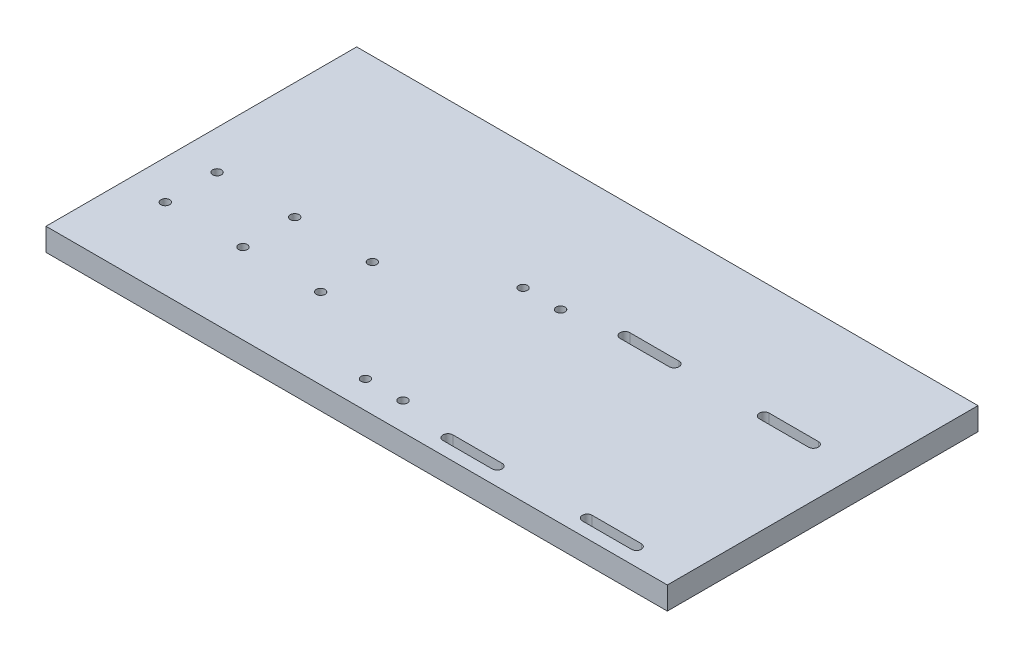
from build123d import *

# Parameters (mm, degrees)
SKETCH1_W                                      = 304.8
SKETCH1_H                                      = 152.4
BOSS_EXTRUDE1_DEPTH                            = 11.1125
CUT_EXTRUDE1_DEPTH                             = 11.1125
CUT_EXTRUDE2_REACH                             = 143.224
SKETCH5_W                                      = 24.13
SKETCH5_H                                      = 2.677814457
SKETCH5_H_2                                    = 2.54
CBORE_FOR_8_SOCKET_HEAD_CAP_SCREW1_D           = 4.3053
CBORE_FOR_8_SOCKET_HEAD_CAP_SCREW1_DEPTH       = 11.1125
CBORE_FOR_8_SOCKET_HEAD_CAP_SCREW1_CBORE_D     = 7.9375
CBORE_FOR_8_SOCKET_HEAD_CAP_SCREW1_CBORE_DEPTH = 4.1656
CBORE_FOR_8_SOCKET_HEAD_CAP_SCREW3_D           = 4.3053
CBORE_FOR_8_SOCKET_HEAD_CAP_SCREW3_DEPTH       = 11.1125
CBORE_FOR_8_SOCKET_HEAD_CAP_SCREW3_CBORE_D     = 7.9375
CBORE_FOR_8_SOCKET_HEAD_CAP_SCREW3_CBORE_DEPTH = 4.1656


with BuildPart() as part:
    # Sketch1 → Boss-Extrude1 (new body)
    with BuildSketch(Plane(origin=(0, 0, 0), x_dir=(1, 0, 0), z_dir=(0, 1, 0))):
        with Locations((152.4, 76.2)):
            Rectangle(SKETCH1_W, SKETCH1_H)
    extrude(amount=BOSS_EXTRUDE1_DEPTH)

    # Sketch3 → Cut-Extrude1 (cut)
    with BuildSketch(Plane(origin=(0, 11.1125, 0), x_dir=(1, 0, 0), z_dir=(0, 1, 0))):
        with BuildLine():
            Line((280.86812, 11.176), (256.73812, 11.176))
            ThreePointArc((256.73812, 11.176), (254.32512, 8.763), (256.73812, 6.35))
            Line((256.73812, 6.35), (280.86812, 6.35))
            ThreePointArc((280.86812, 6.35), (283.28112, 8.763), (280.86812, 11.176))
        make_face()
        with BuildLine():
            Line((280.86812, 97.9932), (256.73812, 97.9932))
            ThreePointArc((256.73812, 97.9932), (254.32512, 95.5802), (256.73812, 93.1672))
            Line((256.73812, 93.1672), (280.86812, 93.1672))
            ThreePointArc((280.86812, 93.1672), (283.28112, 95.5802), (280.86812, 97.9932))
        make_face()
        with BuildLine():
            Line((212.54212, 97.9932), (188.41212, 97.9932))
            ThreePointArc((188.41212, 97.9932), (185.99912, 95.5802), (188.41212, 93.1672))
            Line((188.41212, 93.1672), (212.54212, 93.1672))
            ThreePointArc((212.54212, 93.1672), (214.95512, 95.5802), (212.54212, 97.9932))
        make_face()
        with BuildLine():
            ThreePointArc((212.54212, 6.35), (214.95512, 8.763), (212.54212, 11.176))
            Line((212.54212, 11.176), (188.41212, 11.176))
            ThreePointArc((188.41212, 11.176), (185.99912, 8.763), (188.41212, 6.35))
            Line((188.41212, 6.35), (212.54212, 6.35))
        make_face()
    extrude(amount=-CUT_EXTRUDE1_DEPTH, mode=Mode.SUBTRACT)

    # Sketch5 → Cut-Extrude2 (cut, up to next)
    with BuildSketch(Plane.XY.offset(-11.176), mode=Mode.PRIVATE) as cut_extrude2_sk1:
        with Locations((200.47712, 1.338907229)):
            Rectangle(SKETCH5_W, SKETCH5_H)
    cut_extrude2_tool1 = extrude(cut_extrude2_sk1.sketch, amount=-CUT_EXTRUDE2_REACH, mode=Mode.PRIVATE) & part.part
    add(cut_extrude2_tool1.solids().sort_by_distance((200.47712, 1.338907, -11.176))[0], mode=Mode.SUBTRACT)
    # Sketch5 → Cut-Extrude2 (cut, up to next)
    with BuildSketch(Plane.XY.offset(-11.176), mode=Mode.PRIVATE) as cut_extrude2_sk2:
        with Locations((268.80312, 1.27)):
            Rectangle(SKETCH5_W, SKETCH5_H_2)
    cut_extrude2_tool2 = extrude(cut_extrude2_sk2.sketch, amount=-CUT_EXTRUDE2_REACH, mode=Mode.PRIVATE) & part.part
    add(cut_extrude2_tool2.solids().sort_by_distance((268.80312, 1.27, -11.176))[0], mode=Mode.SUBTRACT)

    # CBORE for #8 Socket Head Cap Screw1
    with Locations(Plane(origin=(161.6075, 0, -13.516787713), x_dir=(0, 0, -1), z_dir=(0, -1, 0))):
        with Locations((0, 0), (0, -18.415), (77.309624574, 0), (77.309624574, -18.415)):
            CounterBoreHole(CBORE_FOR_8_SOCKET_HEAD_CAP_SCREW1_D / 2, CBORE_FOR_8_SOCKET_HEAD_CAP_SCREW1_CBORE_D / 2, CBORE_FOR_8_SOCKET_HEAD_CAP_SCREW1_CBORE_DEPTH, depth=CBORE_FOR_8_SOCKET_HEAD_CAP_SCREW1_DEPTH)

    # CBORE for #8 Socket Head Cap Screw3
    with Locations(Plane(origin=(95.25, 0, -39.4716), x_dir=(0, 0, -1), z_dir=(0, -1, 0))):
        with Locations((0, 0), (25.4, 0), (0, -38.1), (25.4, -38.1), (0, -76.2), (25.4, -76.2)):
            CounterBoreHole(CBORE_FOR_8_SOCKET_HEAD_CAP_SCREW3_D / 2, CBORE_FOR_8_SOCKET_HEAD_CAP_SCREW3_CBORE_D / 2, CBORE_FOR_8_SOCKET_HEAD_CAP_SCREW3_CBORE_DEPTH, depth=CBORE_FOR_8_SOCKET_HEAD_CAP_SCREW3_DEPTH)


solid = part.part
